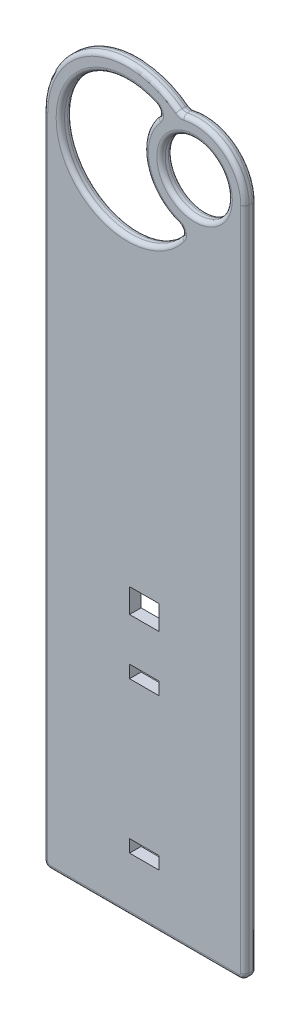
from build123d import *

# Parameters (mm, degrees)
SKETCH1_R           = 50.8
SKETCH1_W           = 44.45
SKETCH1_H           = 19.05
SKETCH1_H_2         = 36.5125
BOSS_EXTRUDE1_DEPTH = 17.4625
FILLET1_R           = 6.35


with BuildPart() as part:
    # Sketch1 → Boss-Extrude1 (new body)
    with BuildSketch(Plane.XY):
        with BuildLine():
            Line((-142.875, 0), (142.875, 0))
            ThreePointArc((142.875, 0), (149.610192091, 2.789807909), (152.4, 9.525))
            Line((152.4, 9.525), (152.4, 1016))
            ThreePointArc((152.4, 1016), (123.632058256, 1075.637570789), (59.049872713, 1090.244953593))
            ThreePointArc((59.049872713, 1090.244953593), (54.920178074, 1090.209902549), (51.163820281, 1091.926114225))
            ThreePointArc((51.163820281, 1091.926114225), (-81.992379453, 1104.293898639), (-152.4, 990.6))
            Line((-152.4, 990.6), (-152.4, 9.525))
            ThreePointArc((-152.4, 9.525), (-149.610192091, 2.789807909), (-142.875, 0))
        make_face()
        with Locations((76.2, 1016)):
            Circle(SKETCH1_R, mode=Mode.SUBTRACT)
        with Locations((0, 320.675)):
            Rectangle(SKETCH1_W, SKETCH1_H, mode=Mode.SUBTRACT)
        with Locations((0, 413.54375)):
            Rectangle(SKETCH1_W, SKETCH1_H_2, mode=Mode.SUBTRACT)
        with Locations((0, 92.075)):
            Rectangle(SKETCH1_W, SKETCH1_H, mode=Mode.SUBTRACT)
        with BuildLine():
            ThreePointArc((17.234168155, 1082.821948069), (-123.966478015, 965.958380496), (55.616947464, 929.290830835))
            ThreePointArc((55.616947464, 929.290830835), (57.137833169, 937.799013835), (51.152541012, 944.034280395))
            ThreePointArc((51.152541012, 944.034280395), (2.275141489, 997.518785372), (20.233079903, 1067.712124834))
            ThreePointArc((20.233079903, 1067.712124834), (22.579976954, 1076.030438696), (17.234168155, 1082.821948069))
        make_face(mode=Mode.SUBTRACT)
    extrude(amount=BOSS_EXTRUDE1_DEPTH)

    # Fillet1
    fillet1_edges = [part.edges().sort_by_distance(p)[0] for p in [
        (123.632058256, 1075.637570789, 17.4625),
        (152.4, 512.7625, 0),
        (149.610192091, 2.789807909, 0),
        (54.920178074, 1090.209902549, 17.4625),
        (-81.992379453, 1104.293898639, 17.4625),
        (-152.4, 500.0625, 17.4625),
        (25.4, 1016, 0),
        (25.4, 1016, 17.4625),
        (-149.610192091, 2.789807909, 17.4625),
        (0, 0, 17.4625),
        (57.137833169, 937.799013835, 0),
        (2.275141489, 997.518785372, 0),
        (22.579976954, 1076.030438696, 0),
        (-123.966478015, 965.958380496, 0),
        (57.137833169, 937.799013835, 17.4625),
        (2.275141489, 997.518785372, 17.4625),
        (22.579976954, 1076.030438696, 17.4625),
        (-123.966478015, 965.958380496, 17.4625),
        (149.610192091, 2.789807909, 17.4625),
        (152.4, 512.7625, 17.4625),
        (0, 0, 0),
        (-149.610192091, 2.789807909, 0),
        (-152.4, 500.0625, 0),
        (-81.992379453, 1104.293898639, 0),
        (54.920178074, 1090.209902549, 0),
        (123.632058256, 1075.637570789, 0),
    ]]
    fillet(fillet1_edges, radius=FILLET1_R)


solid = part.part
